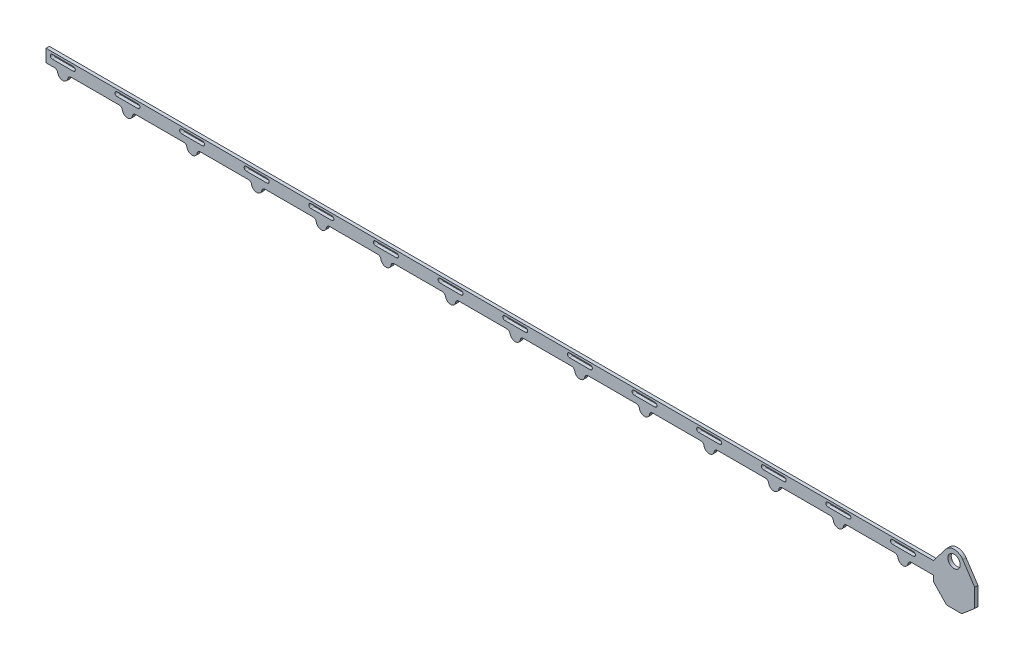
from build123d import *

# Parameters (mm, degrees)
BOSS_EXTRUDE1_DEPTH     = 5.08
CUT_EXTRUDE4_DEPTH      = 1417.935748787
CUT_EXTRUDE7_DEPTH      = 1417.935748787
CUT_EXTRUDE7_DEPTH_BACK = 1417.935748787
SKETCH1_4_R             = 9.398


with BuildPart() as part:
    # Sketch1 → Boss-Extrude1 (new body)
    with BuildSketch(Plane.XY):
        with BuildLine():
            Line((0, 0), (12.898944119, 0))
            ThreePointArc((12.898944119, 0), (16.172901968, -1.195724006), (17.905619663, -4.22))
            ThreePointArc((17.905619663, -4.22), (25.6159, -10.7188), (33.326180337, -4.22))
            ThreePointArc((33.326180337, -4.22), (35.058898032, -1.195724006), (38.332855881, 0))
            Line((38.332855881, 0), (111.450944119, 0))
            ThreePointArc((111.450944119, 0), (114.724901968, -1.195724006), (116.457619663, -4.22))
            ThreePointArc((116.457619663, -4.22), (124.1679, -10.7188), (131.878180337, -4.22))
            ThreePointArc((131.878180337, -4.22), (133.610898032, -1.195724006), (136.884855881, 0))
            Line((136.884855881, 0), (210.002944119, 0))
            ThreePointArc((210.002944119, 0), (213.276901968, -1.195724006), (215.009619663, -4.22))
            ThreePointArc((215.009619663, -4.22), (222.7199, -10.7188), (230.430180337, -4.22))
            ThreePointArc((230.430180337, -4.22), (232.162898032, -1.195724006), (235.436855881, 0))
            Line((235.436855881, 0), (308.554944119, 0))
            ThreePointArc((308.554944119, 0), (311.828901968, -1.195724006), (313.561619663, -4.22))
            ThreePointArc((313.561619663, -4.22), (321.2719, -10.7188), (328.982180337, -4.22))
            ThreePointArc((328.982180337, -4.22), (330.714898032, -1.195724006), (333.988855881, 0))
            Line((333.988855881, 0), (407.106944119, 0))
            ThreePointArc((407.106944119, 0), (410.380901968, -1.195724006), (412.113619663, -4.22))
            ThreePointArc((412.113619663, -4.22), (419.8239, -10.7188), (427.534180337, -4.22))
            ThreePointArc((427.534180337, -4.22), (429.266898032, -1.195724006), (432.540855881, 0))
            Line((432.540855881, 0), (505.658944119, 0))
            ThreePointArc((505.658944119, 0), (508.932901968, -1.195724006), (510.665619663, -4.22))
            ThreePointArc((510.665619663, -4.22), (518.3759, -10.7188), (526.086180337, -4.22))
            ThreePointArc((526.086180337, -4.22), (527.818898032, -1.195724006), (531.092855881, 0))
            Line((531.092855881, 0), (604.210944119, 0))
            ThreePointArc((604.210944119, 0), (607.484901968, -1.195724006), (609.217619663, -4.22))
            ThreePointArc((609.217619663, -4.22), (616.9279, -10.7188), (624.638180337, -4.22))
            ThreePointArc((624.638180337, -4.22), (626.370898032, -1.195724006), (629.644855881, 0))
            Line((629.644855881, 0), (702.762944119, 0))
            ThreePointArc((702.762944119, 0), (706.036901968, -1.195724006), (707.769619663, -4.22))
            ThreePointArc((707.769619663, -4.22), (715.4799, -10.7188), (723.190180337, -4.22))
            ThreePointArc((723.190180337, -4.22), (724.922898032, -1.195724006), (728.196855881, 0))
            Line((728.196855881, 0), (801.314944119, 0))
            ThreePointArc((801.314944119, 0), (804.588901968, -1.195724006), (806.321619663, -4.22))
            ThreePointArc((806.321619663, -4.22), (814.0319, -10.7188), (821.742180337, -4.22))
            ThreePointArc((821.742180337, -4.22), (823.474898032, -1.195724006), (826.748855881, 0))
            Line((826.748855881, 0), (899.866944119, 0))
            ThreePointArc((899.866944119, 0), (903.140901968, -1.195724006), (904.873619663, -4.22))
            ThreePointArc((904.873619663, -4.22), (912.5839, -10.7188), (920.294180337, -4.22))
            ThreePointArc((920.294180337, -4.22), (922.026898032, -1.195724006), (925.300855881, 0))
            Line((925.300855881, 0), (998.418944119, 0))
            ThreePointArc((998.418944119, 0), (1001.692901968, -1.195724006), (1003.425619663, -4.22))
            ThreePointArc((1003.425619663, -4.22), (1011.1359, -10.7188), (1018.846180337, -4.22))
            ThreePointArc((1018.846180337, -4.22), (1020.578898032, -1.195724006), (1023.852855881, 0))
            Line((1023.852855881, 0), (1096.970944119, 0))
            ThreePointArc((1096.970944119, 0), (1100.244901968, -1.195724006), (1101.977619663, -4.22))
            ThreePointArc((1101.977619663, -4.22), (1109.6879, -10.7188), (1117.398180337, -4.22))
            ThreePointArc((1117.398180337, -4.22), (1119.130898032, -1.195724006), (1122.404855881, 0))
            Line((1122.404855881, 0), (1195.522944119, 0))
            ThreePointArc((1195.522944119, 0), (1198.796901968, -1.195724006), (1200.529619663, -4.22))
            ThreePointArc((1200.529619663, -4.22), (1208.2399, -10.7188), (1215.950180337, -4.22))
            ThreePointArc((1215.950180337, -4.22), (1217.682898032, -1.195724006), (1220.956855881, 0))
            Line((1220.956855881, 0), (1294.074944119, 0))
            ThreePointArc((1294.074944119, 0), (1297.348901968, -1.195724006), (1299.081619663, -4.22))
            ThreePointArc((1299.081619663, -4.22), (1306.7919, -10.7188), (1314.502180337, -4.22))
            ThreePointArc((1314.502180337, -4.22), (1316.234898032, -1.195724006), (1319.508855881, 0))
            Line((1319.508855881, 0), (1353.185, 0))
            Line((1353.185, 0), (1353.185, -8.6614))
            Line((1353.185, -8.6614), (1373.0986, -29.4894))
            Line((1373.0986, -29.4894), (1396.1364, -29.4894))
            Line((1396.1364, -29.4894), (1416.05, -12.7762))
            Line((1416.05, -12.7762), (1416.05, 15.367))
            Line((1416.05, 15.367), (1397.95671204, 42.671885143))
            ThreePointArc((1397.95671204, 42.671885143), (1385.175201607, 49.825078541), (1371.926438397, 43.57964356))
            Line((1371.926438397, 43.57964356), (1353.185, 19.177))
            Line((1353.185, 19.177), (0, 19.177))
            Line((0, 19.177), (0, 0))
        make_face()
    extrude(amount=BOSS_EXTRUDE1_DEPTH)

    # Sketch2 → Cut-Extrude4 (cut, through all)
    with BuildSketch(Plane.XY.offset(5.08)):
        with BuildLine():
            Line((9.7409, 15.9512), (41.4909, 15.9512))
            ThreePointArc((41.4909, 15.9512), (44.6659, 12.7762), (41.4909, 9.6012))
            Line((41.4909, 9.6012), (9.7409, 9.6012))
            ThreePointArc((9.7409, 9.6012), (6.5659, 12.7762), (9.7409, 15.9512))
        make_face()
        with BuildLine():
            Line((108.2929, 15.9512), (140.0429, 15.9512))
            ThreePointArc((140.0429, 15.9512), (143.2179, 12.7762), (140.0429, 9.6012))
            Line((140.0429, 9.6012), (108.2929, 9.6012))
            ThreePointArc((108.2929, 9.6012), (105.1179, 12.7762), (108.2929, 15.9512))
        make_face()
        with BuildLine():
            Line((206.8449, 15.9512), (238.5949, 15.9512))
            ThreePointArc((238.5949, 15.9512), (241.7699, 12.7762), (238.5949, 9.6012))
            Line((238.5949, 9.6012), (206.8449, 9.6012))
            ThreePointArc((206.8449, 9.6012), (203.6699, 12.7762), (206.8449, 15.9512))
        make_face()
        with BuildLine():
            Line((305.3969, 15.9512), (337.1469, 15.9512))
            ThreePointArc((337.1469, 15.9512), (340.3219, 12.7762), (337.1469, 9.6012))
            Line((337.1469, 9.6012), (305.3969, 9.6012))
            ThreePointArc((305.3969, 9.6012), (302.2219, 12.7762), (305.3969, 15.9512))
        make_face()
        with BuildLine():
            Line((403.9489, 15.9512), (435.6989, 15.9512))
            ThreePointArc((435.6989, 15.9512), (438.8739, 12.7762), (435.6989, 9.6012))
            Line((435.6989, 9.6012), (403.9489, 9.6012))
            ThreePointArc((403.9489, 9.6012), (400.7739, 12.7762), (403.9489, 15.9512))
        make_face()
        with BuildLine():
            Line((502.5009, 15.9512), (534.2509, 15.9512))
            ThreePointArc((534.2509, 15.9512), (537.4259, 12.7762), (534.2509, 9.6012))
            Line((534.2509, 9.6012), (502.5009, 9.6012))
            ThreePointArc((502.5009, 9.6012), (499.3259, 12.7762), (502.5009, 15.9512))
        make_face()
        with BuildLine():
            Line((601.0529, 15.9512), (632.8029, 15.9512))
            ThreePointArc((632.8029, 15.9512), (635.9779, 12.7762), (632.8029, 9.6012))
            Line((632.8029, 9.6012), (601.0529, 9.6012))
            ThreePointArc((601.0529, 9.6012), (597.8779, 12.7762), (601.0529, 15.9512))
        make_face()
        with BuildLine():
            Line((699.6049, 15.9512), (731.3549, 15.9512))
            ThreePointArc((731.3549, 15.9512), (734.5299, 12.7762), (731.3549, 9.6012))
            Line((731.3549, 9.6012), (699.6049, 9.6012))
            ThreePointArc((699.6049, 9.6012), (696.4299, 12.7762), (699.6049, 15.9512))
        make_face()
        with BuildLine():
            Line((798.1569, 15.9512), (829.9069, 15.9512))
            ThreePointArc((829.9069, 15.9512), (833.0819, 12.7762), (829.9069, 9.6012))
            Line((829.9069, 9.6012), (798.1569, 9.6012))
            ThreePointArc((798.1569, 9.6012), (794.9819, 12.7762), (798.1569, 15.9512))
        make_face()
        with BuildLine():
            Line((896.7089, 15.9512), (928.4589, 15.9512))
            ThreePointArc((928.4589, 15.9512), (931.6339, 12.7762), (928.4589, 9.6012))
            Line((928.4589, 9.6012), (896.7089, 9.6012))
            ThreePointArc((896.7089, 9.6012), (893.5339, 12.7762), (896.7089, 15.9512))
        make_face()
        with BuildLine():
            Line((995.2609, 15.9512), (1027.0109, 15.9512))
            ThreePointArc((1027.0109, 15.9512), (1030.1859, 12.7762), (1027.0109, 9.6012))
            Line((1027.0109, 9.6012), (995.2609, 9.6012))
            ThreePointArc((995.2609, 9.6012), (992.0859, 12.7762), (995.2609, 15.9512))
        make_face()
        with BuildLine():
            Line((1093.8129, 15.9512), (1125.5629, 15.9512))
            ThreePointArc((1125.5629, 15.9512), (1128.7379, 12.7762), (1125.5629, 9.6012))
            Line((1125.5629, 9.6012), (1093.8129, 9.6012))
            ThreePointArc((1093.8129, 9.6012), (1090.6379, 12.7762), (1093.8129, 15.9512))
        make_face()
        with BuildLine():
            Line((1192.3649, 15.9512), (1224.1149, 15.9512))
            ThreePointArc((1224.1149, 15.9512), (1227.2899, 12.7762), (1224.1149, 9.6012))
            Line((1224.1149, 9.6012), (1192.3649, 9.6012))
            ThreePointArc((1192.3649, 9.6012), (1189.1899, 12.7762), (1192.3649, 15.9512))
        make_face()
        with BuildLine():
            Line((1290.9169, 15.9512), (1322.6669, 15.9512))
            ThreePointArc((1322.6669, 15.9512), (1325.8419, 12.7762), (1322.6669, 9.6012))
            Line((1322.6669, 9.6012), (1290.9169, 9.6012))
            ThreePointArc((1290.9169, 9.6012), (1287.7419, 12.7762), (1290.9169, 15.9512))
        make_face()
    extrude(amount=-CUT_EXTRUDE4_DEPTH, mode=Mode.SUBTRACT)

    # Sketch1_4 → Cut-Extrude7 (cut, two sides: drawn at the far end of the back side and taken through both)
    with BuildSketch(Plane.XY.offset(-CUT_EXTRUDE7_DEPTH_BACK)):
        with Locations((1384.6175, 33.8328)):
            Circle(SKETCH1_4_R)
    extrude(amount=CUT_EXTRUDE7_DEPTH + CUT_EXTRUDE7_DEPTH_BACK, mode=Mode.SUBTRACT)


solid = part.part
